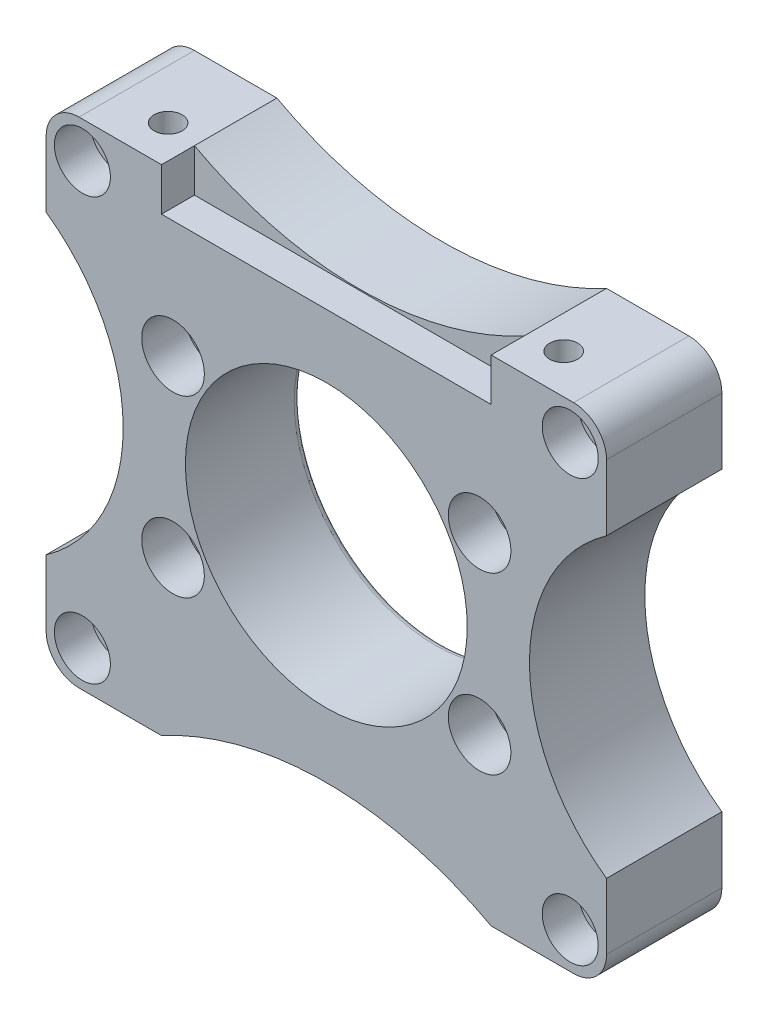
from build123d import *

# Parameters (mm, degrees)
ESQUISSE2_W                   = 170
ESQUISSE2_H                   = 150
BOSS_EXTRU_1_DEPTH            = 35
ESQUISSE3_R                   = 42.75
ENL_V_MAT_EXTRU_2_DEPTH       = 40
ESQUISSE5_R                   = 6
ENL_V_MAT_EXTRU_3_DEPTH       = 40
ESQUISSE6_R                   = 9.5
ENL_V_MAT_EXTRU_4_DEPTH       = 13
ESQUISSE7_R                   = 5.25
ENL_V_MAT_EXTRU_5_DEPTH       = 40
ESQUISSE8_R                   = 8.5
ENL_V_MAT_EXTRU_6_DEPTH       = 11
ESQUISSE9_R                   = 4.25
ENL_V_MAT_EXTRU_7_DEPTH       = 25
ENL_V_MAT_EXTRU_8_DEPTH       = 1
ENL_V_MAT_EXTRU_8_DEPTH_BACK  = 36
ENL_V_MAT_EXTRU_12_DEPTH      = 1
ENL_V_MAT_EXTRU_12_DEPTH_BACK = 36
ENL_V_MAT_EXTRU_13_DEPTH      = 1
ENL_V_MAT_EXTRU_13_DEPTH_BACK = 36
ENL_V_MAT_EXTRU_14_DEPTH      = 1
ENL_V_MAT_EXTRU_14_DEPTH_BACK = 36
CONG_1_R                      = 10
CONG_2_R                      = 10
CONG_3_R                      = 10
CONG_4_R                      = 10
CONG_5_R                      = 2
ENL_V_MAT_EXTRU_17_DEPTH      = 10


with BuildPart() as part:
    # Esquisse2 → Boss.-Extru.1 (new body)
    with BuildSketch(Plane.XY):
        with Locations((-85, 75)):
            Rectangle(ESQUISSE2_W, ESQUISSE2_H)
    extrude(amount=BOSS_EXTRU_1_DEPTH)

    # Esquisse3 → Enlèv. mat.-Extru.2 (cut)
    with BuildSketch(Plane.XY.offset(35)):
        with Locations((-85, 75)):
            Circle(ESQUISSE3_R)
    extrude(amount=-ENL_V_MAT_EXTRU_2_DEPTH, mode=Mode.SUBTRACT)

    # Esquisse5 → Enlèv. mat.-Extru.3 (cut)
    with BuildSketch(Plane.XY.offset(35)):
        with Locations((-38.5, 101.5)):
            Circle(ESQUISSE5_R)
        with Locations((-38.5, 48.5)):
            Circle(ESQUISSE5_R)
        with Locations((-131.5, 48.5)):
            Circle(ESQUISSE5_R)
        with Locations((-131.5, 101.5)):
            Circle(ESQUISSE5_R)
    extrude(amount=-ENL_V_MAT_EXTRU_3_DEPTH, mode=Mode.SUBTRACT)

    # Esquisse6 → Enlèv. mat.-Extru.4 (cut)
    with BuildSketch(Plane.XY.offset(35)):
        with Locations((-38.5, 101.5)):
            Circle(ESQUISSE6_R)
        with Locations((-38.5, 48.5)):
            Circle(ESQUISSE6_R)
        with Locations((-131.5, 48.5)):
            Circle(ESQUISSE6_R)
        with Locations((-131.5, 101.5)):
            Circle(ESQUISSE6_R)
    extrude(amount=-ENL_V_MAT_EXTRU_4_DEPTH, mode=Mode.SUBTRACT)

    # Esquisse7 → Enlèv. mat.-Extru.5 (cut)
    with BuildSketch(Plane.XY.offset(35)):
        with Locations((-11, 139)):
            Circle(ESQUISSE7_R)
        with Locations((-11, 11)):
            Circle(ESQUISSE7_R)
        with Locations((-159, 11)):
            Circle(ESQUISSE7_R)
        with Locations((-159, 139)):
            Circle(ESQUISSE7_R)
    extrude(amount=-ENL_V_MAT_EXTRU_5_DEPTH, mode=Mode.SUBTRACT)

    # Esquisse8 → Enlèv. mat.-Extru.6 (cut)
    with BuildSketch(Plane.XY.offset(35)):
        with Locations((-11, 139)):
            Circle(ESQUISSE8_R)
        with Locations((-11, 11)):
            Circle(ESQUISSE8_R)
        with Locations((-159, 11)):
            Circle(ESQUISSE8_R)
        with Locations((-159, 139)):
            Circle(ESQUISSE8_R)
    extrude(amount=-ENL_V_MAT_EXTRU_6_DEPTH, mode=Mode.SUBTRACT)

    # Esquisse9 → Enlèv. mat.-Extru.7 (cut)
    with BuildSketch(Plane(origin=(0, 150, 0), x_dir=(1, 0, 0), z_dir=(0, 1, 0))):
        with Locations(Location((-25, -23, 0), (0, 0, 270))):  # turned: the seam where the file's is
            Circle(ESQUISSE9_R)
        with Locations(Location((-145, -23, 0), (0, 0, 270))):  # turned: the seam where the file's is
            Circle(ESQUISSE9_R)
    extrude(amount=-ENL_V_MAT_EXTRU_7_DEPTH, mode=Mode.SUBTRACT)

    # Esquisse19 → Enlèv. mat.-Extru.8 (cut, two sides)
    with BuildSketch(Plane.XY.offset(35)) as enl_v_mat_extru_8_sk:
        with BuildLine():
            Line((348.687033491, 365.032270311), (0, 120))
            ThreePointArc((0, 120), (-23.377223398, 75), (0, 30))
            Line((0, 30), (348.687033491, -215.032270311))
            Line((348.687033491, -215.032270311), (1201.033115359, -215.032270311))
            Line((1201.033115359, -215.032270311), (1201.033115359, 365.032270311))
            Line((1201.033115359, 365.032270311), (348.687033491, 365.032270311))
        make_face()
    extrude(amount=ENL_V_MAT_EXTRU_8_DEPTH, mode=Mode.SUBTRACT)
    extrude(enl_v_mat_extru_8_sk.sketch, amount=-ENL_V_MAT_EXTRU_8_DEPTH_BACK, mode=Mode.SUBTRACT)

    # Esquisse22 → Enlèv. mat.-Extru.12 (cut, two sides)
    with BuildSketch(Plane.XY.offset(35)) as enl_v_mat_extru_12_sk:
        with BuildLine():
            Line((-498.703585548, -196.956534006), (-135, 0))
            ThreePointArc((-135, 0), (-85, 12.669073437), (-35, 0))
            Line((-35, 0), (328.703585548, -196.956534006))
            Line((328.703585548, -196.956534006), (328.703585548, -1024.17397683))
            Line((328.703585548, -1024.17397683), (-498.703585548, -1024.17397683))
            Line((-498.703585548, -1024.17397683), (-498.703585548, -196.956534006))
        make_face()
    extrude(amount=ENL_V_MAT_EXTRU_12_DEPTH, mode=Mode.SUBTRACT)
    extrude(enl_v_mat_extru_12_sk.sketch, amount=-ENL_V_MAT_EXTRU_12_DEPTH_BACK, mode=Mode.SUBTRACT)

    # Esquisse27 → Enlèv. mat.-Extru.13 (cut, two sides)
    with BuildSketch(Plane.XY.offset(35)) as enl_v_mat_extru_13_sk:
        with BuildLine():
            Line((-518.687033491, 365.032270311), (-170, 120))
            ThreePointArc((-170, 120), (-146.622776602, 75), (-170, 30))
            Line((-170, 30), (-518.687033491, -215.032270311))
            Line((-518.687033491, -215.032270311), (-1371.033115359, -215.032270311))
            Line((-1371.033115359, -215.032270311), (-1371.033115359, 365.032270311))
            Line((-1371.033115359, 365.032270311), (-518.687033491, 365.032270311))
        make_face()
    extrude(amount=ENL_V_MAT_EXTRU_13_DEPTH, mode=Mode.SUBTRACT)
    extrude(enl_v_mat_extru_13_sk.sketch, amount=-ENL_V_MAT_EXTRU_13_DEPTH_BACK, mode=Mode.SUBTRACT)

    # Esquisse28 → Enlèv. mat.-Extru.14 (cut, two sides)
    with BuildSketch(Plane.XY.offset(35)) as enl_v_mat_extru_14_sk:
        with BuildLine():
            Line((-498.703585548, 346.956534006), (-135, 150))
            ThreePointArc((-135, 150), (-85, 137.330926563), (-35, 150))
            Line((-35, 150), (328.703585548, 346.956534006))
            Line((328.703585548, 346.956534006), (328.703585548, 1174.17397683))
            Line((328.703585548, 1174.17397683), (-498.703585548, 1174.17397683))
            Line((-498.703585548, 1174.17397683), (-498.703585548, 346.956534006))
        make_face()
    extrude(amount=ENL_V_MAT_EXTRU_14_DEPTH, mode=Mode.SUBTRACT)
    extrude(enl_v_mat_extru_14_sk.sketch, amount=-ENL_V_MAT_EXTRU_14_DEPTH_BACK, mode=Mode.SUBTRACT)

    # Congé1
    cong_1_edges = [part.edges().sort_by_distance(p)[0] for p in [
        (0, 150, 17.5),
    ]]
    fillet(cong_1_edges, radius=CONG_1_R)

    # Congé2
    cong_2_edges = [part.edges().sort_by_distance(p)[0] for p in [
        (-170, 150, 17.5),
    ]]
    fillet(cong_2_edges, radius=CONG_2_R)

    # Congé3
    cong_3_edges = [part.edges().sort_by_distance(p)[0] for p in [
        (-170, 0, 17.5),
    ]]
    fillet(cong_3_edges, radius=CONG_3_R)

    # Congé4
    cong_4_edges = [part.edges().sort_by_distance(p)[0] for p in [
        (0, 0, 17.5),
    ]]
    fillet(cong_4_edges, radius=CONG_4_R)

    # Congé5
    cong_5_edges = [part.edges().sort_by_distance(p)[0] for p in [
        (-127.75, 75, 0),
    ]]
    fillet(cong_5_edges, radius=CONG_5_R)

    # Esquisse40 → Enlèv. mat.-Extru.17 (cut)
    with BuildSketch(Plane.XY.offset(35)):
        with BuildLine():
            Line((-135, 150), (-135, 137))
            Line((-135, 137), (-35, 137))
            Line((-35, 137), (-35, 150))
            ThreePointArc((-35, 150), (-85, 137.330926563), (-135, 150))
        make_face()
    extrude(amount=-ENL_V_MAT_EXTRU_17_DEPTH, mode=Mode.SUBTRACT)


solid = part.part
